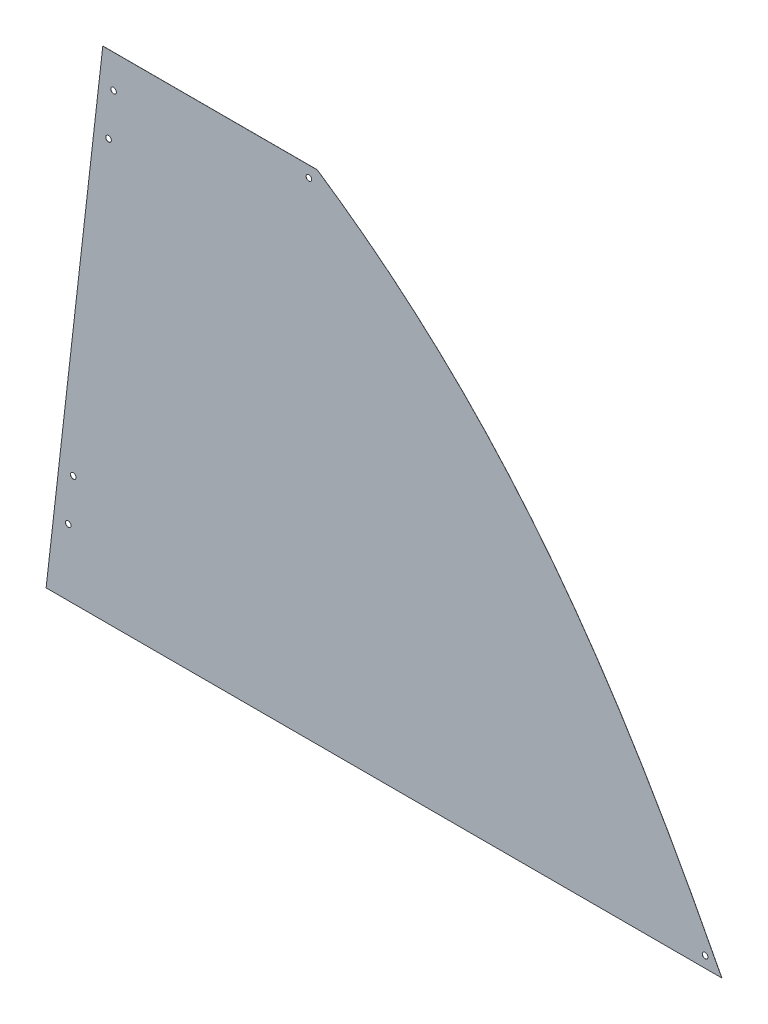
from build123d import *

# Parameters (mm, degrees)
BOSS_EXTRUDE1_DEPTH             = 0.127
BOSS_EXTRUDE2_DEPTH             = 0.127
F_1_4_0_25_DIAMETER_HOLE2_D     = 6.35
F_1_4_0_25_DIAMETER_HOLE3_D     = 6.35
F_1_4_0_25_DIAMETER_HOLE3_DEPTH = 0.127


with BuildPart() as part:
    # Sketch1 → Boss-Extrude1 (new body)
    with BuildSketch(Plane.XY):
        with BuildLine():
            Line((0, 0), (739.14, 0))
            add(Edge.make_bspline(
                [(277.420636668, 567.826315519), (496.859161811, 420.297110317), (620.758181585, 229.590161119), (739.14, 0)],
                knots=[0, 0, 0, 0, 1, 1, 1, 1], degree=3))
            Line((277.420636668, 567.826315519), (64.695636668, 567.826315519))
            Line((64.695636668, 567.826315519), (0, 0))
        make_face()
    extrude(amount=BOSS_EXTRUDE1_DEPTH)

    # Sketch5 → Boss-Extrude2 (add)
    with BuildSketch(Plane(origin=(0, 0, 0), x_dir=(-1, 0, 0), z_dir=(0, 0, -1))):
        Polygon((-64.695636668, 567.826315519), (-32.740222655, 567.826315519), (31.955414013, 0), (0, 0), align=None)
    extrude(amount=-BOSS_EXTRUDE2_DEPTH)

    # 1/4 (0.25) Diameter Hole2 (through all)
    with Locations(Plane.XY.offset(0.127)):
        with Locations((-6.712513837, 75.710175403), (-0.961790578, 126.183625671), (39.293272238, 479.49777755), (45.043995497, 529.971227818)):
            Hole(F_1_4_0_25_DIAMETER_HOLE2_D / 2)

    # 1/4 (0.25) Diameter Hole3
    with Locations(Plane.XY.offset(0.127)):
        with Locations((720.09, 12.7), (267.895636668, 555.126315519)):
            Hole(F_1_4_0_25_DIAMETER_HOLE3_D / 2, depth=F_1_4_0_25_DIAMETER_HOLE3_DEPTH)


solid = part.part
